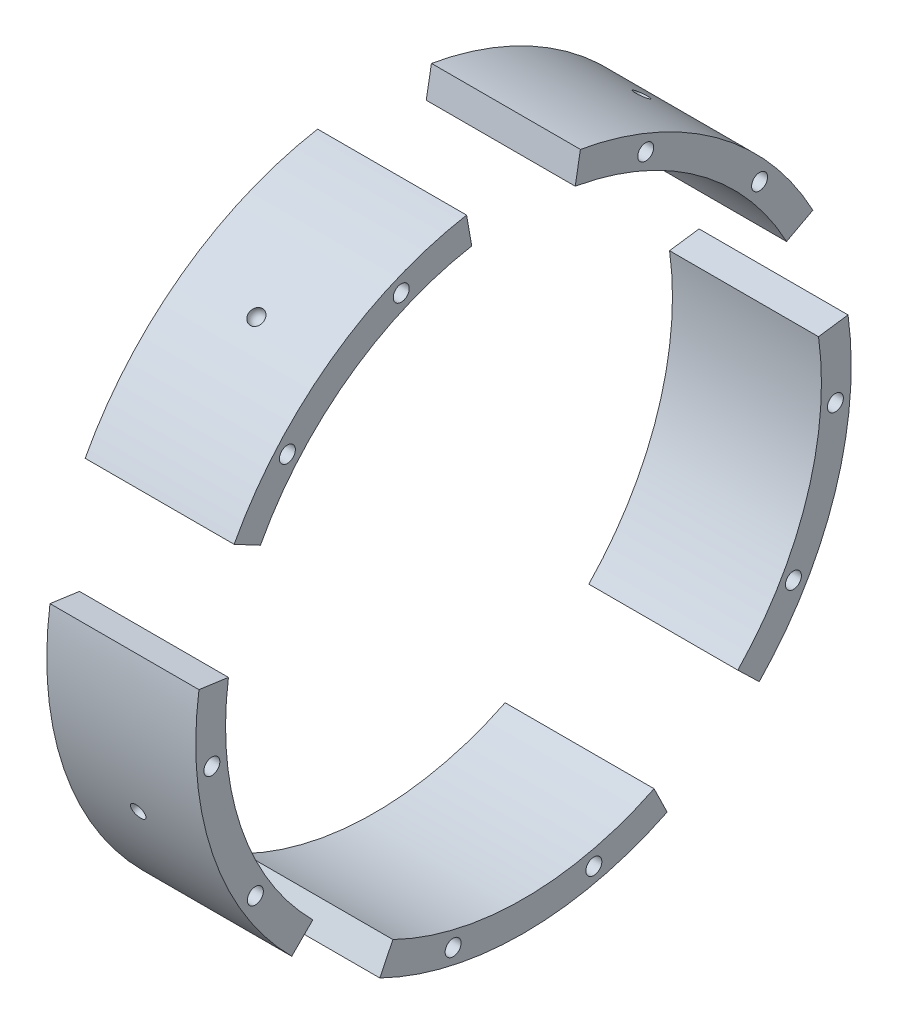
from build123d import *

# Parameters (mm, degrees)
BOSS_EXTRUDE1_DEPTH               = 100
BOSS_EXTRUDE1_2_DEPTH             = 100
BOSS_EXTRUDE1_3_DEPTH             = 100
BOSS_EXTRUDE1_4_DEPTH             = 100
BOSS_EXTRUDE1_5_DEPTH             = 100
F_1_2_13_TAPPED_HOLE3_AT_2_COUNT  = 2
F_1_2_13_TAPPED_HOLE3_AT_2_PITCH  = 94.479443
F_1_2_13_TAPPED_HOLE3_AT_3_COUNT  = 2
F_1_2_13_TAPPED_HOLE3_AT_3_PITCH  = 164.107074
F_1_2_13_TAPPED_HOLE3_AT_4_COUNT  = 2
F_1_2_13_TAPPED_HOLE3_AT_4_PITCH  = 246.869806
F_1_2_13_TAPPED_HOLE3_AT_5_COUNT  = 2
F_1_2_13_TAPPED_HOLE3_AT_5_PITCH  = 360.010266
F_1_2_13_TAPPED_HOLE3_AT_6_COUNT  = 2
F_1_2_13_TAPPED_HOLE3_AT_6_PITCH  = 399.443737
F_1_2_13_TAPPED_HOLE3_AT_7_COUNT  = 2
F_1_2_13_TAPPED_HOLE3_AT_7_PITCH  = 417.711721
F_1_2_13_TAPPED_HOLE3_AT_8_COUNT  = 2
F_1_2_13_TAPPED_HOLE3_AT_8_PITCH  = 398.778039
F_1_2_13_TAPPED_HOLE3_AT_9_COUNT  = 2
F_1_2_13_TAPPED_HOLE3_AT_9_PITCH  = 316.978024
F_1_2_13_TAPPED_HOLE3_AT_10_COUNT = 2
F_1_2_13_TAPPED_HOLE3_AT_10_PITCH = 246.869806


with BuildPart() as part:
    # Sketch1 → Boss-Extrude1 (new body)
    with BuildSketch(Plane(origin=(0, 0, 0), x_dir=(0, 0, -1), z_dir=(1, 0, 0))):
        with BuildLine():
            Line((87.674229, -179.758809), (96.441652, -197.73469))
            ThreePointArc((96.441652, -197.73469), (0, -220), (-96.441652, -197.73469))
            Line((-96.441652, -197.73469), (-87.674229, -179.758809))
            ThreePointArc((-87.674229, -179.758809), (0, -200), (87.674229, -179.758809))
        make_face()
    extrude(amount=BOSS_EXTRUDE1_DEPTH)

    # Sketch6 → Cut-Revolve4 (revolve, cut)
    with BuildSketch(Plane(origin=(0, -220, 0), x_dir=(-1, 0, 0), z_dir=(0, -1, 0))):
        with BuildLine():
            Line((-55, 0), (-45, 0))
            ThreePointArc((-45, 0), (-50, -5), (-55, 0))
        make_face()
    revolve(axis=Axis((55, -220, 0), (-1, 0, 0)), mode=Mode.SUBTRACT)


with BuildPart() as body_2:
    # Sketch1 → Boss-Extrude1 2 (new body)
    with BuildSketch(Plane(origin=(0, 0, 0), x_dir=(0, 0, -1), z_dir=(1, 0, 0))):
        with BuildLine():
            Line((143.86796, -138.931674), (158.254756, -152.824842))
            ThreePointArc((158.254756, -152.824842), (209.232434, -67.983739), (217.858975, 30.618082))
            Line((217.858975, 30.618082), (198.053614, 27.83462))
            ThreePointArc((198.053614, 27.83462), (190.211303, -61.803399), (143.86796, -138.931674))
        make_face()
    extrude(amount=BOSS_EXTRUDE1_2_DEPTH)

    # Sketch5 → Cut-Revolve3 (revolve, cut)
    with BuildSketch(Plane(origin=(0, -67.983739, -209.232434), x_dir=(-1, 0, 0), z_dir=(0, -0.309017, -0.951057))):
        with BuildLine():
            Line((-55, 0), (-45, 0))
            ThreePointArc((-45, 0), (-50, 5), (-55, 0))
        make_face()
    revolve(axis=Axis((55, -67.983739, -209.232434), (-1, 0, 0)), mode=Mode.SUBTRACT)


with BuildPart() as body_3:
    # Sketch1 → Boss-Extrude1 3 (new body)
    with BuildSketch(Plane(origin=(0, 0, 0), x_dir=(0, 0, -1), z_dir=(1, 0, 0))):
        with BuildLine():
            Line((176.589519, 93.894313), (194.24847, 103.283744))
            ThreePointArc((194.24847, 103.283744), (129.312756, 177.983739), (38.202599, 216.657706))
            Line((38.202599, 216.657706), (34.729636, 196.961551))
            ThreePointArc((34.729636, 196.961551), (117.55705, 161.803399), (176.589519, 93.894313))
        make_face()
    extrude(amount=BOSS_EXTRUDE1_3_DEPTH)

    # Sketch4 → Cut-Revolve2 (revolve, cut)
    with BuildSketch(Plane(origin=(0, 177.983739, -129.312756), x_dir=(1, 0, 0), z_dir=(0, 0.809017, -0.587785))):
        with BuildLine():
            Line((45, 0), (55, 0))
            ThreePointArc((55, 0), (50, 5), (45, 0))
        make_face()
    revolve(axis=Axis((45, 177.983739, -129.312756), (1, 0, 0)), mode=Mode.SUBTRACT)


with BuildPart() as body_4:
    # Sketch1 → Boss-Extrude1 4 (new body)
    with BuildSketch(Plane(origin=(0, 0, 0), x_dir=(0, 0, -1), z_dir=(1, 0, 0))):
        with BuildLine():
            Line((-34.729636, 196.961551), (-38.202599, 216.657706))
            ThreePointArc((-38.202599, 216.657706), (-129.312756, 177.983739), (-194.24847, 103.283744))
            Line((-194.24847, 103.283744), (-176.589519, 93.894313))
            ThreePointArc((-176.589519, 93.894313), (-117.55705, 161.803399), (-34.729636, 196.961551))
        make_face()
    extrude(amount=BOSS_EXTRUDE1_4_DEPTH)

    # Sketch2 → Cut-Revolve1 (revolve, cut)
    with BuildSketch(Plane(origin=(0, 177.983739, 129.312756), x_dir=(1, 0, 0), z_dir=(0, 0.809017, 0.587785))):
        with BuildLine():
            Line((45, 0), (55, 0))
            ThreePointArc((55, 0), (50, 5), (45, 0))
        make_face()
    revolve(axis=Axis((45, 177.983739, 129.312756), (1, 0, 0)), mode=Mode.SUBTRACT)

    # Sketch13 → 1/2-13 Tapped Hole3 (revolve, cut)
    with BuildSketch(Plane(origin=(110, 137.772396, 158.489012), x_dir=(0, 0, -1), z_dir=(0, 1, 0))):
        Polygon((0, 0), (0, 69.119489), (5.35813, 65.9), (5.35813, 0), align=None)
    f_1_2_13_tapped_hole3 = revolve(axis=Axis((116.35, 137.772396, 158.489012), (-1, 0, 0)), mode=Mode.SUBTRACT)

    # 1/2-13 Tapped Hole3 at 2: 1/2-13 Tapped Hole3 ×2
    with Locations(*[Vector(0, 0.587785, -0.809017) * (i * F_1_2_13_TAPPED_HOLE3_AT_2_PITCH) for i in range(1, F_1_2_13_TAPPED_HOLE3_AT_2_COUNT)]):
        add(f_1_2_13_tapped_hole3, mode=Mode.SUBTRACT)


with BuildPart() as body_5:
    # Sketch1 → Boss-Extrude1 5 (new body)
    with BuildSketch(Plane(origin=(0, 0, 0), x_dir=(0, 0, -1), z_dir=(1, 0, 0))):
        with BuildLine():
            Line((-198.053614, 27.83462), (-217.858975, 30.618082))
            ThreePointArc((-217.858975, 30.618082), (-208.631204, -69.807024), (-155.563492, -155.563492))
            Line((-155.563492, -155.563492), (-141.421356, -141.421356))
            ThreePointArc((-141.421356, -141.421356), (-189.664731, -63.460931), (-198.053614, 27.83462))
        make_face()
    extrude(amount=BOSS_EXTRUDE1_5_DEPTH)

    # Sketch7 → Cut-Revolve5 (revolve, cut)
    with BuildSketch(Plane(origin=(0, -69.807024, 208.631204), x_dir=(1, 0, 0), z_dir=(0, -0.317305, 0.948324))):
        with BuildLine():
            Line((45, 0), (55, 0))
            ThreePointArc((55, 0), (50, 5), (45, 0))
        make_face()
    revolve(axis=Axis((45, -69.807024, 208.631204), (1, 0, 0)), mode=Mode.SUBTRACT)

    # 1/2-13 Tapped Hole3 at 3: 1/2-13 Tapped Hole3 ×2
    with Locations(*[Vector(0, -0.951057, 0.309017) * (i * F_1_2_13_TAPPED_HOLE3_AT_3_PITCH) for i in range(1, F_1_2_13_TAPPED_HOLE3_AT_3_COUNT)]):
        add(f_1_2_13_tapped_hole3, mode=Mode.SUBTRACT)

    # 1/2-13 Tapped Hole3 at 4: 1/2-13 Tapped Hole3 ×2
    with Locations(*[Vector(0, -0.996195, 0.087156) * (i * F_1_2_13_TAPPED_HOLE3_AT_4_PITCH) for i in range(1, F_1_2_13_TAPPED_HOLE3_AT_4_COUNT)]):
        add(f_1_2_13_tapped_hole3, mode=Mode.SUBTRACT)


with BuildPart() as part_1:
    add(part.part)

    # 1/2-13 Tapped Hole3 at 5: 1/2-13 Tapped Hole3 ×2
    with Locations(*[Vector(0, -0.951057, -0.309017) * (i * F_1_2_13_TAPPED_HOLE3_AT_5_PITCH) for i in range(1, F_1_2_13_TAPPED_HOLE3_AT_5_COUNT)]):
        add(f_1_2_13_tapped_hole3, mode=Mode.SUBTRACT)

    # 1/2-13 Tapped Hole3 at 6: 1/2-13 Tapped Hole3 ×2
    with Locations(*[Vector(0, -0.857167, -0.515038) * (i * F_1_2_13_TAPPED_HOLE3_AT_6_PITCH) for i in range(1, F_1_2_13_TAPPED_HOLE3_AT_6_COUNT)]):
        add(f_1_2_13_tapped_hole3, mode=Mode.SUBTRACT)


with BuildPart() as body_2_1:
    add(body_2.part)

    # 1/2-13 Tapped Hole3 at 7: 1/2-13 Tapped Hole3 ×2
    with Locations(*[Vector(0, -0.581939, -0.813233) * (i * F_1_2_13_TAPPED_HOLE3_AT_7_PITCH) for i in range(1, F_1_2_13_TAPPED_HOLE3_AT_7_COUNT)]):
        add(f_1_2_13_tapped_hole3, mode=Mode.SUBTRACT)

    # 1/2-13 Tapped Hole3 at 8: 1/2-13 Tapped Hole3 ×2
    with Locations(*[Vector(0, -0.386052, -0.922477) * (i * F_1_2_13_TAPPED_HOLE3_AT_8_PITCH) for i in range(1, F_1_2_13_TAPPED_HOLE3_AT_8_COUNT)]):
        add(f_1_2_13_tapped_hole3, mode=Mode.SUBTRACT)


with BuildPart() as body_3_1:
    add(body_3.part)

    # 1/2-13 Tapped Hole3 at 9: 1/2-13 Tapped Hole3 ×2
    with Locations(*[(0, 0, -i * F_1_2_13_TAPPED_HOLE3_AT_9_PITCH) for i in range(1, F_1_2_13_TAPPED_HOLE3_AT_9_COUNT)]):
        add(f_1_2_13_tapped_hole3, mode=Mode.SUBTRACT)

    # 1/2-13 Tapped Hole3 at 10: 1/2-13 Tapped Hole3 ×2
    with Locations(*[Vector(0, 0.224951, -0.97437) * (i * F_1_2_13_TAPPED_HOLE3_AT_10_PITCH) for i in range(1, F_1_2_13_TAPPED_HOLE3_AT_10_COUNT)]):
        add(f_1_2_13_tapped_hole3, mode=Mode.SUBTRACT)


solid = Compound([body_4.part, body_5.part, part_1.part, body_2_1.part, body_3_1.part])
